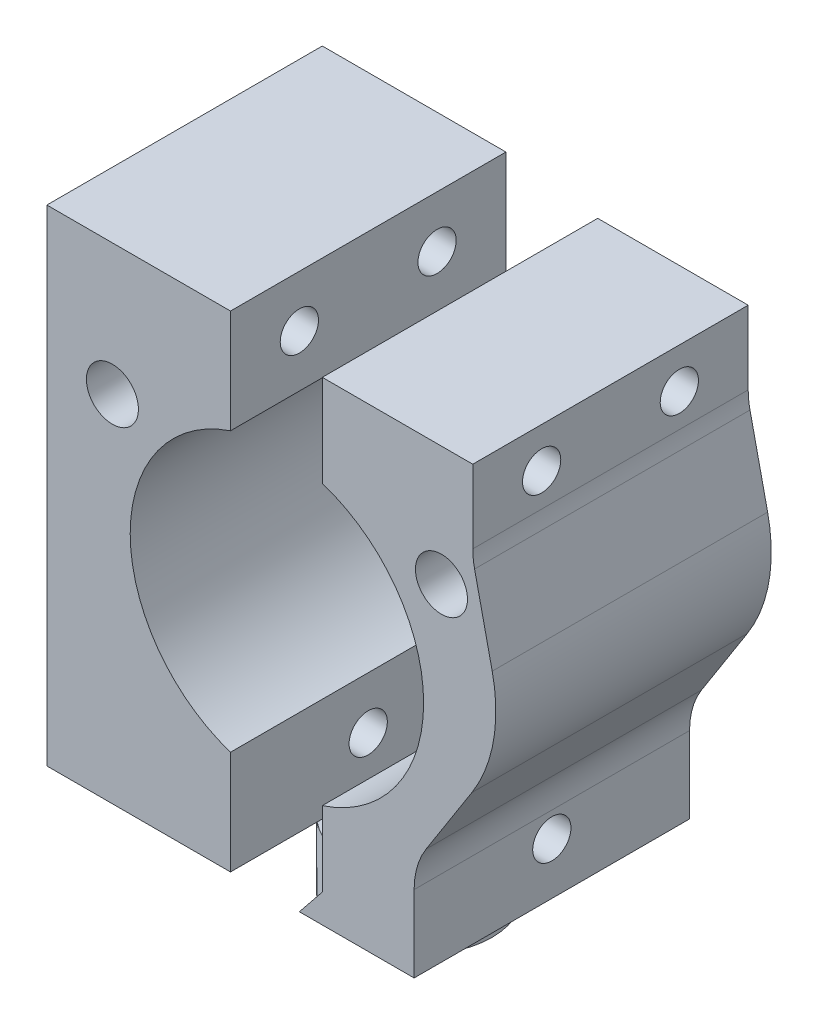
from build123d import *

# Parameters (mm, degrees)
SKETCH2_W                 = 12
SKETCH2_H                 = 18
EXTRUDE1_DEPTH            = 31.75
EXTRUDE1_2_DEPTH          = 31.75
EXTRUDE2_DEPTH            = 4.5
SKETCH4_R                 = 9.5885
MAGNET_CAVITY_DEPTH       = 19
M3X0_5_TAPPED_HOLE1_D     = 2.5
M2X0_4_TAPPED_HOLE2_D     = 1.6
M2X0_4_TAPPED_HOLE2_DEPTH = 6
M2X0_4_TAPPED_HOLE2_TIP   = 0.480688495
M3_CLEARANCE_HOLE1_D      = 3.4
M3_CLEARANCE_HOLE1_DEPTH  = 18
M3_CLEARANCE_HOLE1_TIP    = 1.021463052
EXTRUDE3_DEPTH            = 19
EXTRUDE4_DEPTH            = 18


with BuildPart() as part:
    # Sketch2 → Extrude1 (new body)
    with BuildSketch(Plane(origin=(0, 4.5, 0), x_dir=(-1, 0, 0), z_dir=(0, 1, 0))):
        with Locations((9, 0.343878918)):
            Rectangle(SKETCH2_W, SKETCH2_H)
    extrude(amount=EXTRUDE1_DEPTH)



with BuildPart() as body_2:
    # Sketch2 → Extrude1 2 (new body)
    with BuildSketch(Plane(origin=(0, 4.5, 0), x_dir=(-1, 0, 0), z_dir=(0, 1, 0))):
        with Locations((-9, 0.343878918)):
            Rectangle(SKETCH2_W, SKETCH2_H)
    extrude(amount=EXTRUDE1_2_DEPTH)


with BuildPart() as part_1:
    add(part.part)

    add(body_2.part)  # Extrude2 merges body 2
    # Sketch1 → Extrude2 (add)
    with BuildSketch(Plane(origin=(0, 0, 0), x_dir=(1, 0, 0), z_dir=(0, 1, 0))):
        with BuildLine():
            ThreePointArc((4.75, 0), (3.852758752, 2.778263846), (1.5, 4.506939094))
            Line((1.5, 4.506939094), (1.5, -4.506939094))
            ThreePointArc((1.5, -4.506939094), (3.852758752, -2.778263846), (4.75, 0))
        make_face()
        with BuildLine():
            Line((-1.5, -4.506939094), (-1.5, 4.506939094))
            ThreePointArc((-1.5, 4.506939094), (-4.75, 0), (-1.5, -4.506939094))
        make_face()
    extrude(amount=EXTRUDE2_DEPTH)

    # Sketch4 → Magnet Cavity (cut, through all)
    with BuildSketch(Plane.XY.offset(9.343878918)):
        with Locations((0.033766691, 20.375)):
            Circle(SKETCH4_R)
    extrude(amount=-MAGNET_CAVITY_DEPTH, mode=Mode.SUBTRACT)

    # M3x0.5 Tapped Hole1 (through all)
    with Locations(Plane(origin=(15, 32.871578641, 4.843878918), x_dir=(0, 0, 1), z_dir=(1, 0, 0))):
        with Locations((0, 0), (-9, 0), (-4.5, 24.993157282)):
            Hole(M3X0_5_TAPPED_HOLE1_D / 2)

    # M2x0.4 Tapped Hole2
    with Locations(Plane(origin=(-6.495190528, 4.5, 3.75), x_dir=(0, 0, -1), z_dir=(0, -1, 0))):
        with Locations((0, 0), (0, 12.990381056)):
            Hole(M2X0_4_TAPPED_HOLE2_D / 2, depth=M2X0_4_TAPPED_HOLE2_DEPTH)
            with Locations((0, 0, -(M2X0_4_TAPPED_HOLE2_DEPTH + M2X0_4_TAPPED_HOLE2_TIP / 2))):  # 118° drill point
                Cone(0, M2X0_4_TAPPED_HOLE2_D / 2, M2X0_4_TAPPED_HOLE2_TIP, mode=Mode.SUBTRACT)

    # M3 Clearance Hole1
    with Locations(Plane(origin=(-10.718511689, 27.68174412, 9.343878918), x_dir=(1, 0, 0), z_dir=(0, 0, 1))):
        with Locations((0, 0), (21.50455676, 0)):
            Hole(M3_CLEARANCE_HOLE1_D / 2, depth=M3_CLEARANCE_HOLE1_DEPTH)
            with Locations((0, 0, -(M3_CLEARANCE_HOLE1_DEPTH + M3_CLEARANCE_HOLE1_TIP / 2))):  # 118° drill point
                Cone(0, M3_CLEARANCE_HOLE1_D / 2, M3_CLEARANCE_HOLE1_TIP, mode=Mode.SUBTRACT)

    # Trim Sketch → Extrude3 (cut, through all)
    with BuildSketch(Plane.XY.offset(9.343878918)):
        with BuildLine():
            Line((9, 9.503868704), (9, 4.5))
            Line((9, 4.5), (15, 4.5))
            Line((15, 4.5), (15, 36.25))
            Line((15, 36.25), (3, 36.25))
            Line((3, 36.25), (3, 35.497506653))
            Line((3, 35.497506653), (12.833586371, 35.497506653))
            Line((12.833586371, 35.497506653), (12.833586371, 30.705187388))
            ThreePointArc((12.833586371, 30.705187388), (12.863239183, 30.161451393), (12.951845904, 29.624164718))
            Line((12.951845904, 29.624164718), (14.104451498, 24.419166219))
            ThreePointArc((14.104451498, 24.419166219), (14.188629696, 20.518267921), (12.773591061, 16.882094224))
            Line((12.773591061, 16.882094224), (9.783689751, 12.191382032))
            ThreePointArc((9.783689751, 12.191382032), (9.199919207, 10.903591669), (9, 9.503868704))
        make_face()
    extrude(amount=-EXTRUDE3_DEPTH, mode=Mode.SUBTRACT)

    # Sketch26 → Extrude4 (add)
    with BuildSketch(Plane.XY.offset(9.343878918)):
        Polygon((1.5, 4.5), (3, 6.359966873), (3, 4.5), align=None)
    extrude(amount=-EXTRUDE4_DEPTH)


solid = part_1.part
